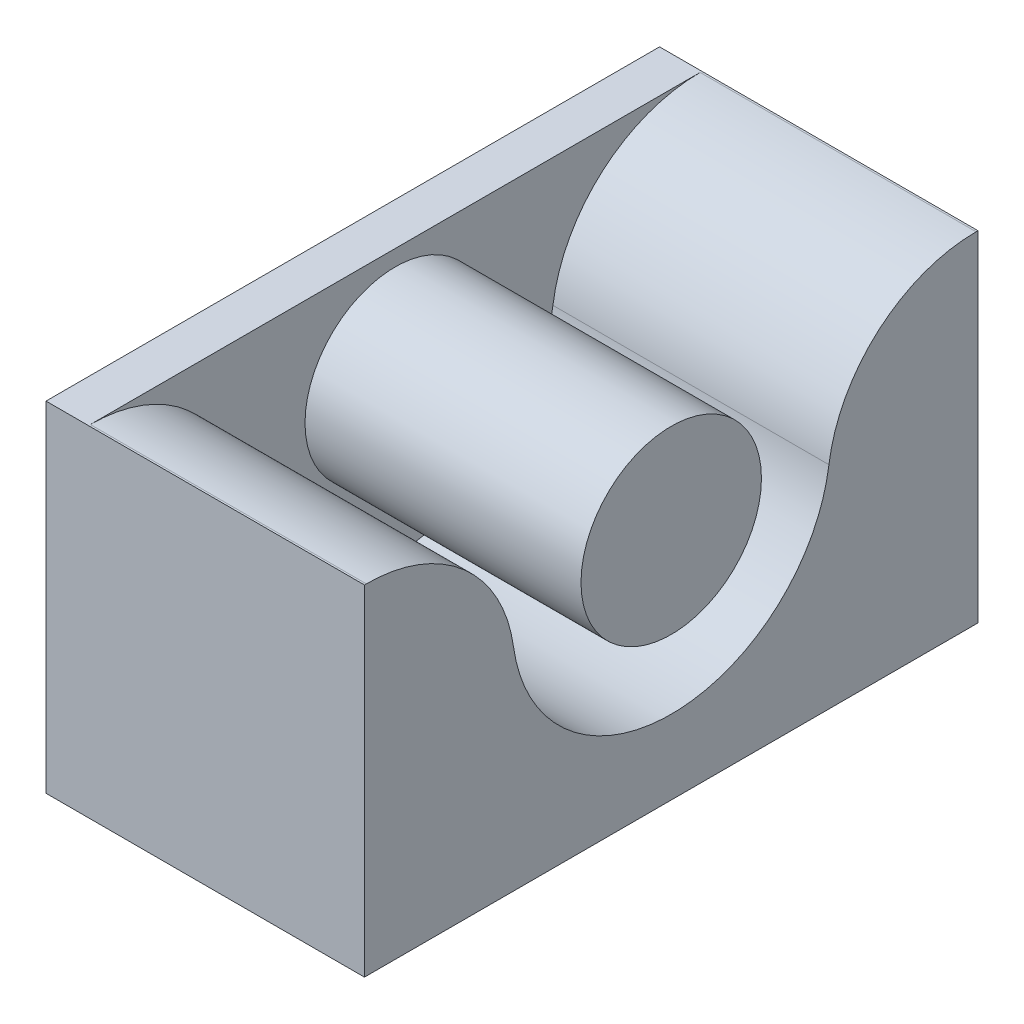
from build123d import *

# Parameters (mm, degrees)
CROQUIS2_R                = 4.25
SALIENTE_EXTRUIR1_DEPTH   = 15
SALIENTE_EXTRUIR1_2_DEPTH = 15
CROQUIS3_W                = 28.9
CROQUIS3_H                = 16
SALIENTE_EXTRUIR2_DEPTH   = 2


with BuildPart() as part:
    # Croquis2 → Saliente-Extruir1 (new body)
    with BuildSketch(Plane(origin=(0, 0, 0), x_dir=(0, 0, -1), z_dir=(1, 0, 0))):
        Circle(CROQUIS2_R)
    extrude(amount=SALIENTE_EXTRUIR1_DEPTH)



with BuildPart() as body_2:
    # Croquis2 → Saliente-Extruir1 2 (new body)
    with BuildSketch(Plane(origin=(0, 0, 0), x_dir=(0, 0, -1), z_dir=(1, 0, 0))):
        with BuildLine():
            Line((-14.45, 5), (-14.361406616, 5))
            ThreePointArc((-14.361406616, 5), (-9.765681466, 3.280086206), (-7.428313767, -1.034482759))
            ThreePointArc((-7.428313767, -1.034482759), (0, -7.5), (7.428313767, -1.034482759))
            ThreePointArc((7.428313767, -1.034482759), (9.765681466, 3.280086206), (14.361406616, 5))
            Line((14.361406616, 5), (14.45, 5))
            Line((14.45, 5), (14.45, -11))
            Line((14.45, -11), (-14.45, -11))
            Line((-14.45, -11), (-14.45, 5))
        make_face()
    extrude(amount=SALIENTE_EXTRUIR1_2_DEPTH)


with BuildPart() as part_1:
    add(part.part)

    add(body_2.part)  # Saliente-Extruir2 merges body 2
    # Croquis3 → Saliente-Extruir2 (add)
    with BuildSketch(Plane.ZY):
        with Locations((0, -3)):
            Rectangle(CROQUIS3_W, CROQUIS3_H)
    extrude(amount=-SALIENTE_EXTRUIR2_DEPTH)


solid = part_1.part
